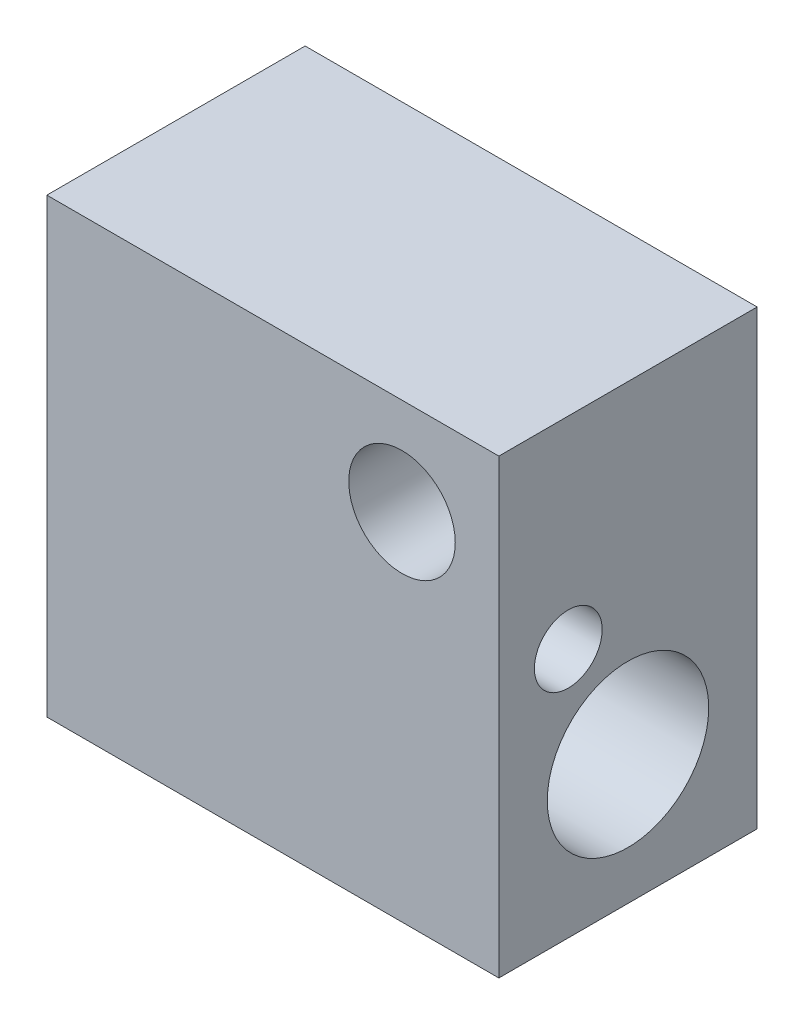
from build123d import *

# Parameters (mm, degrees)
SKETCH1_W                    = 14
SKETCH1_H                    = 14
BOSS_EXTRUDE1_DEPTH          = 8
M4X0_7_TAPPED_HOLE1_D        = 3.3
F_5_0_5_DIAMETER_HOLE1_D     = 5
F_2_1_2_1_DIAMETER_HOLE1_D   = 2.1
F_4_0_4_DIAMETER_HOLE1_D     = 4
F_4_0_4_DIAMETER_HOLE1_DEPTH = 1
F_4_0_4_DIAMETER_HOLE1_TIP   = 1.201721238


with BuildPart() as part:
    # Sketch1 → Boss-Extrude1 (new body)
    with BuildSketch(Plane.XY):
        with Locations((7, 7)):
            Rectangle(SKETCH1_W, SKETCH1_H)
    extrude(amount=BOSS_EXTRUDE1_DEPTH)

    # M4x0.7 Tapped Hole1 (through all)
    with Locations(Plane.XY.offset(8)):
        with Locations((11, 11)):
            Hole(M4X0_7_TAPPED_HOLE1_D / 2)

    # Ø5.0 (5) Diameter Hole1 (through all)
    with Locations(Plane.ZY):
        with Locations((4, 4)):
            Hole(F_5_0_5_DIAMETER_HOLE1_D / 2)

    # Ø2.1 (2.1) Diameter Hole1 (through all)
    with Locations(Plane.ZY):
        with Locations((5.85, 7.75)):
            Hole(F_2_1_2_1_DIAMETER_HOLE1_D / 2)

    # Ø4.0 (4) Diameter Hole1
    with Locations(Plane(origin=(11, 11, 0), x_dir=(-1, 0, 0), z_dir=(0, 0, -1))):
        with Locations((0, 0)):
            Hole(F_4_0_4_DIAMETER_HOLE1_D / 2, depth=F_4_0_4_DIAMETER_HOLE1_DEPTH)
            with Locations((0, 0, -(F_4_0_4_DIAMETER_HOLE1_DEPTH + F_4_0_4_DIAMETER_HOLE1_TIP / 2))):  # 118° drill point
                Cone(0, F_4_0_4_DIAMETER_HOLE1_D / 2, F_4_0_4_DIAMETER_HOLE1_TIP, mode=Mode.SUBTRACT)


solid = part.part
